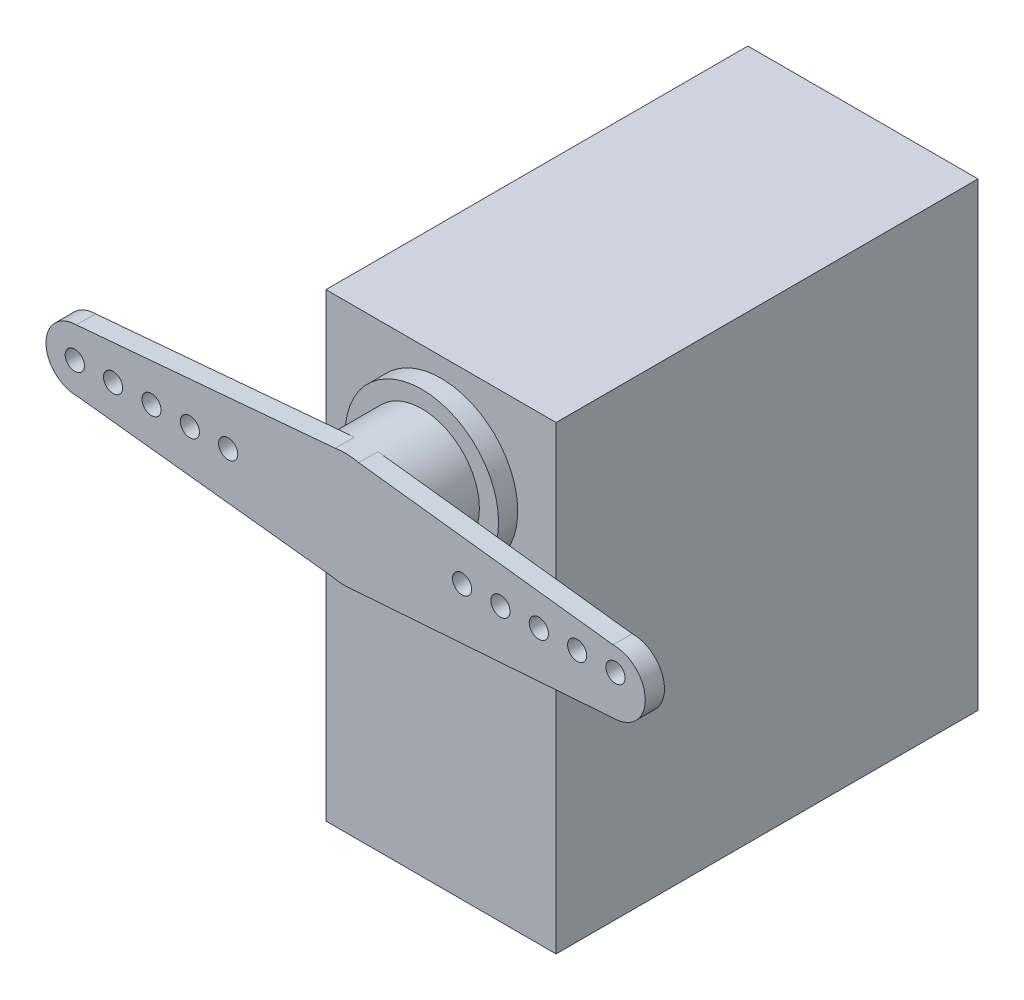
from build123d import *

# Parameters (mm, degrees)
SKETCH1_W               = 19.05
SKETCH1_H               = 38.1
BOSS_EXTRUDE1_DEPTH     = 34.925
SKETCH2_R               = 6.35
BOSS_EXTRUDE2_DEPTH     = 1.5875
SKETCH3_R               = 4.7625
BOSS_EXTRUDE3_DEPTH     = 6.35
BOSS_EXTRUDE4_DEPTH     = 1.5875
SKETCH5_R               = 0.79375
CUT_EXTRUDE1_DEPTH      = 6.35
LPATTERN1_COUNT         = 5
LPATTERN1_PITCH         = 3.175
MIRROR1_COPY_1_SKETCH_R = 0.79375
MIRROR1_COPY_1_DEPTH    = 6.35
MIRROR1_COPY_2_SKETCH_R = 0.79375
MIRROR1_COPY_2_DEPTH    = 6.35
MIRROR1_COPY_3_SKETCH_R = 0.79375
MIRROR1_COPY_3_DEPTH    = 6.35
MIRROR1_COPY_4_SKETCH_R = 0.79375
MIRROR1_COPY_4_DEPTH    = 6.35


with BuildPart() as part:
    # Sketch1 → Boss-Extrude1 (new body)
    with BuildSketch(Plane.XY):
        Rectangle(SKETCH1_W, SKETCH1_H)
    extrude(amount=BOSS_EXTRUDE1_DEPTH)

    # Sketch2 → Boss-Extrude2 (add)
    with BuildSketch(Plane.XY.offset(34.925)):
        with Locations((0, 11.1125)):
            Circle(SKETCH2_R)
    extrude(amount=BOSS_EXTRUDE2_DEPTH)

    # Sketch3 → Boss-Extrude3 (add)
    with BuildSketch(Plane.XY.offset(36.5125)):
        with Locations((0, 11.30801151)):
            Circle(SKETCH3_R)
    extrude(amount=BOSS_EXTRUDE3_DEPTH)

    # Sketch4 → Boss-Extrude4 (add)
    with BuildSketch(Plane.XY.offset(42.8625)):
        with BuildLine():
            Line((0, 16.07051151), (-22.253587721, 14.127262895))
            ThreePointArc((-22.253587721, 14.127262895), (-24.76292538, 11.561183994), (-22.197271079, 9.051412208))
            Line((-22.197271079, 9.051412208), (0, 6.54551151))
            Line((0, 6.54551151), (22.279071817, 8.170731681))
            ThreePointArc((22.279071817, 8.170731681), (24.844676693, 10.840221296), (22.179280362, 13.410078409))
            Line((22.179280362, 13.410078409), (0, 16.07051151))
        make_face()
    extrude(amount=-BOSS_EXTRUDE4_DEPTH)

    # Sketch5 → Cut-Extrude1 (cut)
    with BuildSketch(Plane.XY.offset(42.8625)):
        with Locations((-22.38167538, 11.526576548)):
            Circle(SKETCH5_R)
    cut_extrude1 = extrude(amount=-CUT_EXTRUDE1_DEPTH, mode=Mode.SUBTRACT)

    # LPattern1: Cut-Extrude1 ×5
    with Locations(*[(i * LPATTERN1_PITCH, 0, 0) for i in range(1, LPATTERN1_COUNT)]):
        add(cut_extrude1, mode=Mode.SUBTRACT)

    # Mirror1: Cut-Extrude1 across plane
    add(cut_extrude1.mirror(Plane(origin=(0, 0, 0), x_dir=(0, 0, 1), z_dir=(1, 0, 0))), mode=Mode.SUBTRACT)

    # Mirror1 copy 1 sketch → Mirror1 copy 1 (cut)
    with BuildSketch(Plane(origin=(-3.175, 0, 42.8625), x_dir=(-1, 0, 0), z_dir=(0, 0, 1))):
        with Locations((-22.38167538, -11.526576548)):
            Circle(MIRROR1_COPY_1_SKETCH_R)
    extrude(amount=-MIRROR1_COPY_1_DEPTH, mode=Mode.SUBTRACT)

    # Mirror1 copy 2 sketch → Mirror1 copy 2 (cut)
    with BuildSketch(Plane(origin=(-6.35, 0, 42.8625), x_dir=(-1, 0, 0), z_dir=(0, 0, 1))):
        with Locations((-22.38167538, -11.526576548)):
            Circle(MIRROR1_COPY_2_SKETCH_R)
    extrude(amount=-MIRROR1_COPY_2_DEPTH, mode=Mode.SUBTRACT)

    # Mirror1 copy 3 sketch → Mirror1 copy 3 (cut)
    with BuildSketch(Plane(origin=(-9.525, 0, 42.8625), x_dir=(-1, 0, 0), z_dir=(0, 0, 1))):
        with Locations((-22.38167538, -11.526576548)):
            Circle(MIRROR1_COPY_3_SKETCH_R)
    extrude(amount=-MIRROR1_COPY_3_DEPTH, mode=Mode.SUBTRACT)

    # Mirror1 copy 4 sketch → Mirror1 copy 4 (cut)
    with BuildSketch(Plane(origin=(-12.7, 0, 42.8625), x_dir=(-1, 0, 0), z_dir=(0, 0, 1))):
        with Locations((-22.38167538, -11.526576548)):
            Circle(MIRROR1_COPY_4_SKETCH_R)
    extrude(amount=-MIRROR1_COPY_4_DEPTH, mode=Mode.SUBTRACT)


solid = part.part
